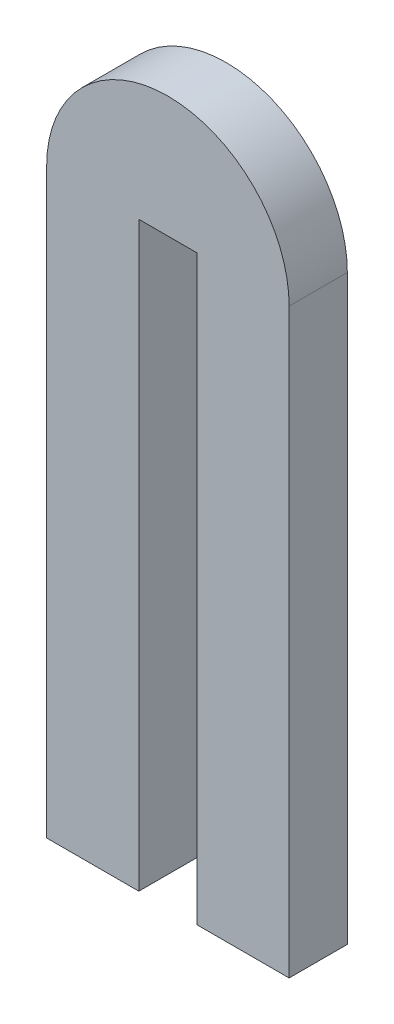
from build123d import *

# Parameters (mm, degrees)
BOSS_EXTRUDE1_DEPTH = 1.5


with BuildPart() as part:
    # Sketch1 → Boss-Extrude1 (new body, symmetric)
    with BuildSketch(Plane.XY):
        with BuildLine():
            Line((1.5, -15), (6.25, -15))
            Line((6.25, -15), (6.25, 15))
            ThreePointArc((6.25, 15), (0, 21.25), (-6.25, 15))
            Line((-6.25, 15), (-6.25, -15))
            Line((-6.25, -15), (-1.5, -15))
            Line((-1.5, -15), (-1.5, 15))
            Line((-1.5, 15), (1.5, 15))
            Line((1.5, 15), (1.5, -15))
        make_face()
    extrude(amount=BOSS_EXTRUDE1_DEPTH, both=True)


solid = part.part
